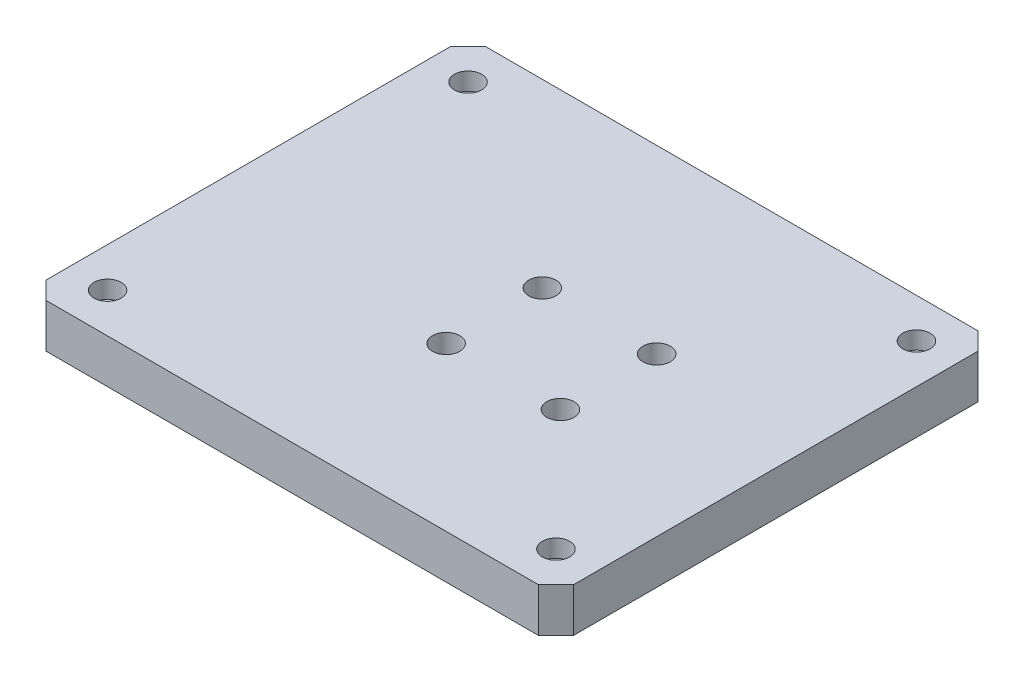
from build123d import *

# Parameters (mm, degrees)
SKETCH1_W           = 60
SKETCH1_H           = 50
BOSS_EXTRUDE1_DEPTH = 5
CHAMFER1_SIZE       = 2
SKETCH2_R           = 1.55
CUT_EXTRUDE1_DEPTH  = 2
CUT_EXTRUDE2_REACH  = 7
SKETCH3_R           = 1.55


with BuildPart() as part:
    # Sketch1 → Boss-Extrude1 (new body)
    with BuildSketch(Plane(origin=(0, 0, 0), x_dir=(1, 0, 0), z_dir=(0, 1, 0))):
        with Locations((30, 25)):
            Rectangle(SKETCH1_W, SKETCH1_H)
    extrude(amount=BOSS_EXTRUDE1_DEPTH)

    # Chamfer1
    chamfer1_edges = [part.edges().sort_by_distance(p)[0] for p in [
        (0, 2.5, -50),
        (60, 2.5, -50),
        (60, 2.5, 0),
        (0, 2.5, 0),
    ]]
    chamfer(chamfer1_edges, length=CHAMFER1_SIZE)

    # Sketch2 → Cut-Extrude1 (cut)
    with BuildSketch(Plane(origin=(0, 5, 0), x_dir=(1, 0, 0), z_dir=(0, 1, 0))):
        with Locations((55.5, 4.5)):
            Circle(SKETCH2_R)
        with Locations((4.5, 4.5)):
            Circle(SKETCH2_R)
        with Locations((4.5, 45.5)):
            Circle(SKETCH2_R)
        with Locations((55.5, 45.5)):
            Circle(SKETCH2_R)
    extrude(amount=-CUT_EXTRUDE1_DEPTH, mode=Mode.SUBTRACT)

    # Sketch3 → Cut-Extrude2 (cut, up to next)
    with BuildSketch(Plane(origin=(0, 5, 0), x_dir=(1, 0, 0), z_dir=(0, 1, 0)), mode=Mode.PRIVATE) as cut_extrude2_sk1:
        with Locations((42, 29.446052378)):
            Circle(SKETCH3_R)
    cut_extrude2_tool1 = extrude(cut_extrude2_sk1.sketch, amount=-CUT_EXTRUDE2_REACH, mode=Mode.PRIVATE) & part.part
    add(cut_extrude2_tool1.solids().sort_by_distance((42, 5, -29.446052))[0], mode=Mode.SUBTRACT)
    # Sketch3 → Cut-Extrude2 (cut, up to next)
    with BuildSketch(Plane(origin=(0, 5, 0), x_dir=(1, 0, 0), z_dir=(0, 1, 0)), mode=Mode.PRIVATE) as cut_extrude2_sk2:
        with Locations((29, 29.446052378)):
            Circle(SKETCH3_R)
    cut_extrude2_tool2 = extrude(cut_extrude2_sk2.sketch, amount=-CUT_EXTRUDE2_REACH, mode=Mode.PRIVATE) & part.part
    add(cut_extrude2_tool2.solids().sort_by_distance((29, 5, -29.446052))[0], mode=Mode.SUBTRACT)
    # Sketch3 → Cut-Extrude2 (cut, up to next)
    with BuildSketch(Plane(origin=(0, 5, 0), x_dir=(1, 0, 0), z_dir=(0, 1, 0)), mode=Mode.PRIVATE) as cut_extrude2_sk3:
        with Locations((42, 18.509029021)):
            Circle(SKETCH3_R)
    cut_extrude2_tool3 = extrude(cut_extrude2_sk3.sketch, amount=-CUT_EXTRUDE2_REACH, mode=Mode.PRIVATE) & part.part
    add(cut_extrude2_tool3.solids().sort_by_distance((42, 5, -18.509029))[0], mode=Mode.SUBTRACT)
    # Sketch3 → Cut-Extrude2 (cut, up to next)
    with BuildSketch(Plane(origin=(0, 5, 0), x_dir=(1, 0, 0), z_dir=(0, 1, 0)), mode=Mode.PRIVATE) as cut_extrude2_sk4:
        with Locations((29, 18.509029021)):
            Circle(SKETCH3_R)
    cut_extrude2_tool4 = extrude(cut_extrude2_sk4.sketch, amount=-CUT_EXTRUDE2_REACH, mode=Mode.PRIVATE) & part.part
    add(cut_extrude2_tool4.solids().sort_by_distance((29, 5, -18.509029))[0], mode=Mode.SUBTRACT)


solid = part.part
